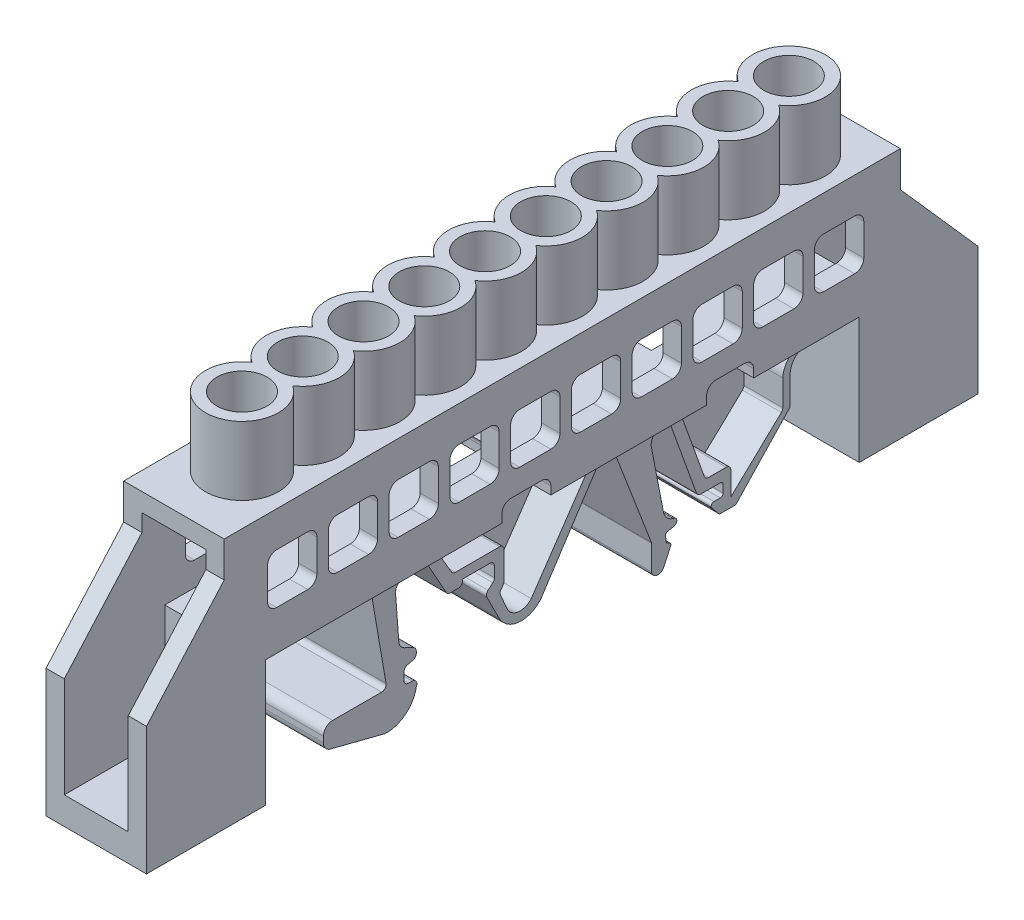
from build123d import *

# Parameters (mm, degrees)
RESSALTO_EXTRUS_O1_DEPTH = 5.5
RESSALTO_EXTRUS_O2_DEPTH = 1
RESSALTO_EXTRUS_O3_DEPTH = 5.25
ESBO_O4_W                = 7
ESBO_O4_H                = 22.5
CORTE_EXTRUS_O1_DEPTH    = 11
ESBO_O5_W                = 7
ESBO_O5_H                = 22.5
CORTE_EXTRUS_O2_DEPTH    = 11
ESBO_O6_W                = 7
ESBO_O6_H                = 10
CORTE_EXTRUS_O3_DEPTH    = 81
ESBO_O7_R                = 2.75
RESSALTO_EXTRUS_O4_DEPTH = 7.5
CORTE_EXTRUS_O4_START    = -3.5
ESBO_O8_R                = 2.75
CORTE_EXTRUS_O4_DEPTH    = 3.5


with BuildPart() as part:
    # Esboço3 → Ressalto-extrusão1 (new, symmetric)
    with BuildSketch(Plane(origin=(0, 0, 0), x_dir=(0, 0, -1), z_dir=(1, 0, 0))):
        with BuildLine():
            Line((0, 14), (0, 0))
            Line((0, 0), (13, 0))
            Line((13, 0), (13, 13.789846595))
            Line((13, 13.789846595), (24.898592819, 13.789846595))
            Line((24.898592819, 13.789846595), (28.503498501, 13.789846595))
            Line((28.503498501, 13.789846595), (30.949413604, 13.789846595))
            Line((30.949413604, 13.789846595), (32.400788305, 13.789846595))
            Line((32.400788305, 13.789846595), (38.891429615, 13.789846595))
            Line((38.891429615, 13.789846595), (38.891429615, 14.669041884))
            ThreePointArc((38.891429615, 14.669041884), (39.184322834, 15.376148665), (39.891429615, 15.669041884))
            Line((39.891429615, 15.669041884), (43.249413604, 15.669041884))
            ThreePointArc((43.249413604, 15.669041884), (43.956520385, 15.376148665), (44.249413604, 14.669041884))
            Line((44.249413604, 14.669041884), (44.249413604, 13.789846595))
            Line((44.249413604, 13.789846595), (48.485767482, 13.789846595))
            Line((48.485767482, 13.789846595), (49.643077993, 13.789846595))
            Line((49.643077993, 13.789846595), (51.577962763, 13.789846595))
            Line((51.577962763, 13.789846595), (55.993250373, 13.789846595))
            Line((55.993250373, 13.789846595), (57.549413604, 13.789846595))
            Line((57.549413604, 13.789846595), (58.827872279, 13.789846595))
            Line((58.827872279, 13.789846595), (61.295441706, 13.789846595))
            Line((61.295441706, 13.789846595), (61.295441706, 14.669041884))
            ThreePointArc((61.295441706, 14.669041884), (61.588334925, 15.376148665), (62.295441706, 15.669041884))
            Line((62.295441706, 15.669041884), (65.449294419, 15.669041884))
            ThreePointArc((65.449294419, 15.669041884), (66.1564012, 15.376148665), (66.449294419, 14.669041884))
            Line((66.449294419, 14.669041884), (66.449294419, 13.789846595))
            Line((66.449294419, 13.789846595), (70.849413604, 13.789846595))
            Line((70.849413604, 13.789846595), (72.110349122, 13.789846595))
            Line((72.110349122, 13.789846595), (78, 13.789846595))
            Line((78, 13.789846595), (78, 0))
            Line((78, 0), (91, 0))
            Line((91, 0), (91, 14))
            Line((91, 14), (82.5, 23.613035938))
            Line((82.5, 23.613035938), (82.5, 27.5))
            Line((82.5, 27.5), (8.5, 27.5))
            Line((8.5, 27.5), (8.5, 23.613035938))
            Line((8.5, 23.613035938), (0, 14))
        make_face()
        with BuildLine():
            ThreePointArc((13.249294419, 22.613035938), (13.542187638, 23.320142719), (14.249294419, 23.613035938))
            Line((14.249294419, 23.613035938), (17.649413604, 23.613035938))
            ThreePointArc((17.649413604, 23.613035938), (18.356520385, 23.320142719), (18.649413604, 22.613035938))
            Line((18.649413604, 22.613035938), (18.649413604, 19.138668257))
            ThreePointArc((18.649413604, 19.138668257), (18.356520385, 18.431561476), (17.649413604, 18.138668257))
            Line((17.649413604, 18.138668257), (14.249294419, 18.138668257))
            ThreePointArc((14.249294419, 18.138668257), (13.542187638, 18.431561476), (13.249294419, 19.138668257))
            Line((13.249294419, 19.138668257), (13.249294419, 22.613035938))
        make_face(mode=Mode.SUBTRACT)
        with BuildLine():
            ThreePointArc((24.299413604, 23.613035938), (25.006520385, 23.320142719), (25.299413604, 22.613035938))
            Line((25.299413604, 22.613035938), (25.299413604, 19.138668257))
            ThreePointArc((25.299413604, 19.138668257), (25.006520385, 18.431561476), (24.299413604, 18.138668257))
            Line((24.299413604, 18.138668257), (20.899294419, 18.138668257))
            ThreePointArc((20.899294419, 18.138668257), (20.192187638, 18.431561476), (19.899294419, 19.138668257))
            Line((19.899294419, 19.138668257), (19.899294419, 22.613035938))
            ThreePointArc((19.899294419, 22.613035938), (20.192187638, 23.320142719), (20.899294419, 23.613035938))
            Line((20.899294419, 23.613035938), (24.299413604, 23.613035938))
        make_face(mode=Mode.SUBTRACT)
        with BuildLine():
            ThreePointArc((30.949413604, 23.613035938), (31.656520385, 23.320142719), (31.949413604, 22.613035938))
            Line((31.949413604, 22.613035938), (31.949413604, 19.138668257))
            ThreePointArc((31.949413604, 19.138668257), (31.656520385, 18.431561476), (30.949413604, 18.138668257))
            Line((30.949413604, 18.138668257), (27.549294419, 18.138668257))
            ThreePointArc((27.549294419, 18.138668257), (26.842187638, 18.431561476), (26.549294419, 19.138668257))
            Line((26.549294419, 19.138668257), (26.549294419, 22.613035938))
            ThreePointArc((26.549294419, 22.613035938), (26.842187638, 23.320142719), (27.549294419, 23.613035938))
            Line((27.549294419, 23.613035938), (30.949413604, 23.613035938))
        make_face(mode=Mode.SUBTRACT)
        with BuildLine():
            ThreePointArc((37.599413604, 23.613035938), (38.306520385, 23.320142719), (38.599413604, 22.613035938))
            Line((38.599413604, 22.613035938), (38.599413604, 19.138668257))
            ThreePointArc((38.599413604, 19.138668257), (38.306520385, 18.431561476), (37.599413604, 18.138668257))
            Line((37.599413604, 18.138668257), (34.199294419, 18.138668257))
            ThreePointArc((34.199294419, 18.138668257), (33.492187638, 18.431561476), (33.199294419, 19.138668257))
            Line((33.199294419, 19.138668257), (33.199294419, 22.613035938))
            ThreePointArc((33.199294419, 22.613035938), (33.492187638, 23.320142719), (34.199294419, 23.613035938))
            Line((34.199294419, 23.613035938), (37.599413604, 23.613035938))
        make_face(mode=Mode.SUBTRACT)
        with BuildLine():
            ThreePointArc((44.249413604, 23.613035938), (44.956520385, 23.320142719), (45.249413604, 22.613035938))
            Line((45.249413604, 22.613035938), (45.249413604, 19.138668257))
            ThreePointArc((45.249413604, 19.138668257), (44.956520385, 18.431561476), (44.249413604, 18.138668257))
            Line((44.249413604, 18.138668257), (40.849294419, 18.138668257))
            ThreePointArc((40.849294419, 18.138668257), (40.142187638, 18.431561476), (39.849294419, 19.138668257))
            Line((39.849294419, 19.138668257), (39.849294419, 22.613035938))
            ThreePointArc((39.849294419, 22.613035938), (40.142187638, 23.320142719), (40.849294419, 23.613035938))
            Line((40.849294419, 23.613035938), (44.249413604, 23.613035938))
        make_face(mode=Mode.SUBTRACT)
        with BuildLine():
            ThreePointArc((50.899413604, 23.613035938), (51.606520385, 23.320142719), (51.899413604, 22.613035938))
            Line((51.899413604, 22.613035938), (51.899413604, 19.138668257))
            ThreePointArc((51.899413604, 19.138668257), (51.606520385, 18.431561476), (50.899413604, 18.138668257))
            Line((50.899413604, 18.138668257), (47.499294419, 18.138668257))
            ThreePointArc((47.499294419, 18.138668257), (46.792187638, 18.431561476), (46.499294419, 19.138668257))
            Line((46.499294419, 19.138668257), (46.499294419, 22.613035938))
            ThreePointArc((46.499294419, 22.613035938), (46.792187638, 23.320142719), (47.499294419, 23.613035938))
            Line((47.499294419, 23.613035938), (50.899413604, 23.613035938))
        make_face(mode=Mode.SUBTRACT)
        with BuildLine():
            ThreePointArc((57.549413604, 23.613035938), (58.256520385, 23.320142719), (58.549413604, 22.613035938))
            Line((58.549413604, 22.613035938), (58.549413604, 19.138668257))
            ThreePointArc((58.549413604, 19.138668257), (58.256520385, 18.431561476), (57.549413604, 18.138668257))
            Line((57.549413604, 18.138668257), (54.149294419, 18.138668257))
            ThreePointArc((54.149294419, 18.138668257), (53.442187638, 18.431561476), (53.149294419, 19.138668257))
            Line((53.149294419, 19.138668257), (53.149294419, 22.613035938))
            ThreePointArc((53.149294419, 22.613035938), (53.442187638, 23.320142719), (54.149294419, 23.613035938))
            Line((54.149294419, 23.613035938), (57.549413604, 23.613035938))
        make_face(mode=Mode.SUBTRACT)
        with BuildLine():
            ThreePointArc((64.199413604, 23.613035938), (64.906520385, 23.320142719), (65.199413604, 22.613035938))
            Line((65.199413604, 22.613035938), (65.199413604, 19.138668257))
            ThreePointArc((65.199413604, 19.138668257), (64.906520385, 18.431561476), (64.199413604, 18.138668257))
            Line((64.199413604, 18.138668257), (60.799294419, 18.138668257))
            ThreePointArc((60.799294419, 18.138668257), (60.092187638, 18.431561476), (59.799294419, 19.138668257))
            Line((59.799294419, 19.138668257), (59.799294419, 22.613035938))
            ThreePointArc((59.799294419, 22.613035938), (60.092187638, 23.320142719), (60.799294419, 23.613035938))
            Line((60.799294419, 23.613035938), (64.199413604, 23.613035938))
        make_face(mode=Mode.SUBTRACT)
        with BuildLine():
            ThreePointArc((70.849413604, 23.613035938), (71.556520385, 23.320142719), (71.849413604, 22.613035938))
            Line((71.849413604, 22.613035938), (71.849413604, 19.138668257))
            ThreePointArc((71.849413604, 19.138668257), (71.556520385, 18.431561476), (70.849413604, 18.138668257))
            Line((70.849413604, 18.138668257), (67.449294419, 18.138668257))
            ThreePointArc((67.449294419, 18.138668257), (66.742187638, 18.431561476), (66.449294419, 19.138668257))
            Line((66.449294419, 19.138668257), (66.449294419, 22.613035938))
            ThreePointArc((66.449294419, 22.613035938), (66.742187638, 23.320142719), (67.449294419, 23.613035938))
            Line((67.449294419, 23.613035938), (70.849413604, 23.613035938))
        make_face(mode=Mode.SUBTRACT)
        with BuildLine():
            ThreePointArc((77.499413604, 23.613035938), (78.206520385, 23.320142719), (78.499413604, 22.613035938))
            Line((78.499413604, 22.613035938), (78.499413604, 19.138668257))
            ThreePointArc((78.499413604, 19.138668257), (78.206520385, 18.431561476), (77.499413604, 18.138668257))
            Line((77.499413604, 18.138668257), (74.099294419, 18.138668257))
            ThreePointArc((74.099294419, 18.138668257), (73.392187638, 18.431561476), (73.099294419, 19.138668257))
            Line((73.099294419, 19.138668257), (73.099294419, 22.613035938))
            ThreePointArc((73.099294419, 22.613035938), (73.392187638, 23.320142719), (74.099294419, 23.613035938))
            Line((74.099294419, 23.613035938), (77.499413604, 23.613035938))
        make_face(mode=Mode.SUBTRACT)
    extrude(amount=RESSALTO_EXTRUS_O1_DEPTH, both=True)

    # Esboço3<3> → Ressalto-extrusão2 (add, symmetric)
    with BuildSketch(Plane(origin=(0, 0, 0), x_dir=(0, 0, -1), z_dir=(1, 0, 0))):
        with BuildLine():
            ThreePointArc((69.885872586, 11.94547112), (70.159995656, 12.976138301), (70.849413604, 13.789846595))
            Line((70.849413604, 13.789846595), (66.449294419, 13.789846595))
            Line((66.449294419, 13.789846595), (66.449294419, 14.669041884))
            ThreePointArc((66.449294419, 14.669041884), (66.1564012, 15.376148665), (65.449294419, 15.669041884))
            Line((65.449294419, 15.669041884), (62.295441706, 15.669041884))
            ThreePointArc((62.295441706, 15.669041884), (61.588334925, 15.376148665), (61.295441706, 14.669041884))
            Line((61.295441706, 14.669041884), (61.295441706, 13.789846595))
            Line((61.295441706, 13.789846595), (58.827872279, 13.789846595))
            Line((58.827872279, 13.789846595), (61.295441706, 6.909975208))
            ThreePointArc((61.295441706, 6.909975208), (61.478336907, 6.669876612), (61.766085315, 6.578778622))
            Line((61.766085315, 6.578778622), (63.699413604, 6.578778622))
            ThreePointArc((63.699413604, 6.578778622), (64.052966995, 6.432332013), (64.199413604, 6.078778622))
            Line((64.199413604, 6.078778622), (64.199413604, 3.510661599))
            Line((64.199413604, 3.510661599), (69.729952437, 8.756124271))
            ThreePointArc((69.729952437, 8.756124271), (69.845241678, 8.921470268), (69.885872586, 9.118903896))
            Line((69.885872586, 9.118903896), (69.885872586, 11.94547112))
        make_face()
        with BuildLine():
            Line((38.891429615, 13.789846595), (32.400788305, 13.789846595))
            Line((32.400788305, 13.789846595), (33.621500031, 11.693837186))
            ThreePointArc((33.621500031, 11.693837186), (33.804383568, 11.511986999), (34.053565261, 11.44547112))
            Line((34.053565261, 11.44547112), (38.891429615, 11.44547112))
            ThreePointArc((38.891429615, 11.44547112), (39.244983006, 11.29902451), (39.391429615, 10.94547112))
            Line((39.391429615, 10.94547112), (39.391429615, 7.946992131))
            ThreePointArc((39.391429615, 7.946992131), (39.364512563, 7.785151083), (39.286659517, 7.640735172))
            Line((39.286659517, 7.640735172), (39.0539077, 7.340364928))
            ThreePointArc((39.0539077, 7.340364928), (38.95320027, 7.097717426), (38.989410815, 6.837508676))
            Line((38.989410815, 6.837508676), (39.722412451, 5.123461371))
            ThreePointArc((39.722412451, 5.123461371), (40.952270853, 4.251004104), (42.356081951, 4.801501857))
            Line((42.356081951, 4.801501857), (48.485767482, 13.789846595))
            Line((48.485767482, 13.789846595), (44.249413604, 13.789846595))
            Line((44.249413604, 13.789846595), (44.249413604, 14.669041884))
            ThreePointArc((44.249413604, 14.669041884), (43.956520385, 15.376148665), (43.249413604, 15.669041884))
            Line((43.249413604, 15.669041884), (39.891429615, 15.669041884))
            ThreePointArc((39.891429615, 15.669041884), (39.184322834, 15.376148665), (38.891429615, 14.669041884))
            Line((38.891429615, 14.669041884), (38.891429615, 13.789846595))
        make_face()
    extrude(amount=RESSALTO_EXTRUS_O2_DEPTH, both=True)

    # Esboço3<4> → Ressalto-extrusão3 (add, symmetric)
    with BuildSketch(Plane(origin=(0, 0, 0), x_dir=(0, 0, -1), z_dir=(1, 0, 0))):
        with BuildLine():
            Line((20.364830397, 1.535810208), (26.343264803, 0))
            Line((26.343264803, 0), (26.73674434, 0))
            ThreePointArc((26.73674434, 0), (28.72569851, 0.827209584), (29.774052255, 2.709008938))
            ThreePointArc((29.774052255, 2.709008938), (29.775216781, 3.23479491), (29.321640723, 3.500729119))
            Line((29.321640723, 3.500729119), (28.916817659, 3.500729119))
            ThreePointArc((28.916817659, 3.500729119), (28.563264268, 3.647175729), (28.416817659, 4.000729119))
            Line((28.416817659, 4.000729119), (28.416817659, 4.801501857))
            ThreePointArc((28.416817659, 4.801501857), (28.524770774, 5.111823046), (28.80201462, 5.288143679))
            Line((28.80201462, 5.288143679), (29.390019819, 5.42685922))
            ThreePointArc((29.390019819, 5.42685922), (29.667263665, 5.603179852), (29.775216781, 5.913501041))
            Line((29.775216781, 5.913501041), (29.775216781, 6.130093383))
            ThreePointArc((29.775216781, 6.130093383), (29.699669067, 6.394366456), (29.495855754, 6.578778622))
            Line((29.495855754, 6.578778622), (28.419840727, 7.107904232))
            ThreePointArc((28.419840727, 7.107904232), (28.032516369, 7.445437035), (27.863900389, 7.930738182))
            Line((27.863900389, 7.930738182), (27.506280217, 12.715310068))
            ThreePointArc((27.506280217, 12.715310068), (27.770512646, 13.470090475), (28.503498501, 13.789846595))
            Line((28.503498501, 13.789846595), (24.898592819, 13.789846595))
            Line((24.898592819, 13.789846595), (26.465396769, 4.707797613))
            ThreePointArc((26.465396769, 4.707797613), (26.355102519, 4.300693531), (25.972675193, 4.122794976))
            Line((25.972675193, 4.122794976), (20.613643263, 4.122794976))
            ThreePointArc((20.613643263, 4.122794976), (19.906536482, 3.829901757), (19.613643263, 3.122794976))
            Line((19.613643263, 3.122794976), (19.613643263, 2.504361785))
            ThreePointArc((19.613643263, 2.504361785), (19.823449342, 1.891504896), (20.364830397, 1.535810208))
        make_face()
        with BuildLine():
            Line((32.400788305, 13.789846595), (30.949413604, 13.789846595))
            Line((30.949413604, 13.789846595), (33.056122431, 10.026029802))
            ThreePointArc((33.056122431, 10.026029802), (33.239548281, 9.838902414), (33.49242626, 9.770240712))
            Line((33.49242626, 9.770240712), (34.358917872, 9.770240712))
            ThreePointArc((34.358917872, 9.770240712), (34.712471263, 9.916687322), (34.858917872, 10.270240712))
            Line((34.858917872, 10.270240712), (34.858917872, 10.409230932))
            Line((34.858917872, 10.409230932), (37.827721923, 10.409230932))
            ThreePointArc((37.827721923, 10.409230932), (38.181275314, 10.262784323), (38.327721923, 9.909230932))
            Line((38.327721923, 9.909230932), (38.327721923, 8.784603909))
            ThreePointArc((38.327721923, 8.784603909), (38.281453321, 8.574537683), (38.151210647, 8.403349341))
            Line((38.151210647, 8.403349341), (37.623691652, 7.955757466))
            ThreePointArc((37.623691652, 7.955757466), (37.457180698, 7.674003227), (37.50060785, 7.34961853))
            Line((37.50060785, 7.34961853), (38.873777842, 4.622794976))
            ThreePointArc((38.873777842, 4.622794976), (41.077358627, 3.236599568), (43.4495558, 4.308973829))
            Line((43.4495558, 4.308973829), (49.643077993, 13.789846595))
            Line((49.643077993, 13.789846595), (48.485767482, 13.789846595))
            Line((48.485767482, 13.789846595), (42.356081951, 4.801501857))
            ThreePointArc((42.356081951, 4.801501857), (40.952270853, 4.251004104), (39.722412451, 5.123461371))
            Line((39.722412451, 5.123461371), (38.989410815, 6.837508676))
            ThreePointArc((38.989410815, 6.837508676), (38.95320027, 7.097717426), (39.0539077, 7.340364928))
            Line((39.0539077, 7.340364928), (39.286659517, 7.640735172))
            ThreePointArc((39.286659517, 7.640735172), (39.364512563, 7.785151083), (39.391429615, 7.946992131))
            Line((39.391429615, 7.946992131), (39.391429615, 10.94547112))
            ThreePointArc((39.391429615, 10.94547112), (39.244983006, 11.29902451), (38.891429615, 11.44547112))
            Line((38.891429615, 11.44547112), (34.053565261, 11.44547112))
            ThreePointArc((34.053565261, 11.44547112), (33.804383568, 11.511986999), (33.621500031, 11.693837186))
            Line((33.621500031, 11.693837186), (32.400788305, 13.789846595))
        make_face()
        with BuildLine():
            ThreePointArc((70.680059627, 11.94547112), (71.112564532, 13.086842425), (72.110349122, 13.789846595))
            Line((72.110349122, 13.789846595), (70.849413604, 13.789846595))
            ThreePointArc((70.849413604, 13.789846595), (70.159995656, 12.976138301), (69.885872586, 11.94547112))
            Line((69.885872586, 11.94547112), (69.885872586, 9.118903896))
            ThreePointArc((69.885872586, 9.118903896), (69.845241678, 8.921470268), (69.729952437, 8.756124271))
            Line((69.729952437, 8.756124271), (64.199413604, 3.510661599))
            Line((64.199413604, 3.510661599), (64.199413604, 6.078778622))
            ThreePointArc((64.199413604, 6.078778622), (64.052966995, 6.432332013), (63.699413604, 6.578778622))
            Line((63.699413604, 6.578778622), (61.766085315, 6.578778622))
            ThreePointArc((61.766085315, 6.578778622), (61.478336907, 6.669876612), (61.295441706, 6.909975208))
            Line((61.295441706, 6.909975208), (58.827872279, 13.789846595))
            Line((58.827872279, 13.789846595), (57.549413604, 13.789846595))
            Line((57.549413604, 13.789846595), (60.437343422, 5.757688627))
            ThreePointArc((60.437343422, 5.757688627), (60.620266317, 5.51784498), (60.907855176, 5.42685922))
            Line((60.907855176, 5.42685922), (63.049825964, 5.42685922))
            ThreePointArc((63.049825964, 5.42685922), (63.261957998, 5.338991254), (63.349825964, 5.12685922))
            Line((63.349825964, 5.12685922), (63.349825964, 4.300729119))
            ThreePointArc((63.349825964, 4.300729119), (63.261957998, 4.088597085), (63.049825964, 4.000729119))
            Line((63.049825964, 4.000729119), (62.351813887, 4.000729119))
            ThreePointArc((62.351813887, 4.000729119), (62.080686374, 3.829142016), (62.119705426, 3.510661599))
            Line((62.119705426, 3.510661599), (62.857536224, 2.609630372))
            ThreePointArc((62.857536224, 2.609630372), (62.961231789, 2.52857038), (63.089644685, 2.499697892))
            Line((63.089644685, 2.499697892), (64.606237924, 2.499697892))
            ThreePointArc((64.606237924, 2.499697892), (64.724886526, 2.524157498), (64.824187808, 2.593547831))
            Line((64.824187808, 2.593547831), (70.598009512, 8.697857327))
            ThreePointArc((70.598009512, 8.697857327), (70.65879334, 8.793068138), (70.680059627, 8.904007388))
            Line((70.680059627, 8.904007388), (70.680059627, 11.94547112))
        make_face()
        with BuildLine():
            Line((55.993250373, 13.789846595), (51.577962763, 13.789846595))
            Line((51.577962763, 13.789846595), (55.508936607, 3.543968186))
            ThreePointArc((55.508936607, 3.543968186), (55.521343576, 3.499954353), (55.525525876, 3.45441691))
            Line((55.525525876, 3.45441691), (55.525525876, 0.750710808))
            ThreePointArc((55.525525876, 0.750710808), (56.056326367, 0.137710586), (56.810855647, 0.434702164))
            Line((56.810855647, 0.434702164), (57.613675208, 2.167772962))
            ThreePointArc((57.613675208, 2.167772962), (57.621538409, 2.35895304), (57.491913801, 2.499697892))
            Line((57.491913801, 2.499697892), (57.275171343, 2.600100649))
            ThreePointArc((57.275171343, 2.600100649), (57.179454624, 2.678014405), (57.132675687, 2.792224627))
            Line((57.132675687, 2.792224627), (57.045319323, 3.415149953))
            ThreePointArc((57.045319323, 3.415149953), (57.088883788, 3.594363833), (57.243481821, 3.694936819))
            Line((57.243481821, 3.694936819), (58.052215107, 3.85800806))
            ThreePointArc((58.052215107, 3.85800806), (58.280744844, 4.302029048), (57.898005118, 4.622794976))
            ThreePointArc((57.898005118, 4.622794976), (57.180067867, 5.066456588), (56.810855647, 5.825371511))
            Line((56.810855647, 5.825371511), (55.525525876, 12.471135232))
            ThreePointArc((55.525525876, 12.471135232), (55.553034674, 13.203680973), (55.993250373, 13.789846595))
        make_face()
    extrude(amount=RESSALTO_EXTRUS_O3_DEPTH, both=True)

    # Esboço4 → Corte-extrusão1 (cut)
    with BuildSketch(Plane.XY):
        with Locations((0, 14.25)):
            Rectangle(ESBO_O4_W, ESBO_O4_H)
    extrude(amount=-CORTE_EXTRUS_O1_DEPTH, mode=Mode.SUBTRACT)

    # Esboço5 → Corte-extrusão2 (cut)
    with BuildSketch(Plane(origin=(0, 0, -91), x_dir=(-1, 0, 0), z_dir=(0, 0, -1))):
        with Locations((0, 14.25)):
            Rectangle(ESBO_O5_W, ESBO_O5_H)
    extrude(amount=-CORTE_EXTRUS_O2_DEPTH, mode=Mode.SUBTRACT)

    # Esboço6 → Corte-extrusão3 (cut)
    with BuildSketch(Plane(origin=(0, 0, -80), x_dir=(-1, 0, 0), z_dir=(0, 0, -1))):
        with Locations((0, 20.5)):
            Rectangle(ESBO_O6_W, ESBO_O6_H)
    extrude(amount=-CORTE_EXTRUS_O3_DEPTH, mode=Mode.SUBTRACT)

    # Esboço7 → Ressalto-extrusão4 (add)
    with BuildSketch(Plane(origin=(0, 27.5, 0), x_dir=(1, 0, 0), z_dir=(0, 1, 0))):
        with BuildLine():
            ThreePointArc((-2.223595062, 19.274354011), (0, 11.949354011), (2.223595062, 19.274354011))
            ThreePointArc((2.223595062, 19.274354011), (4, 22.599354011), (2.223595062, 25.924354011))
            ThreePointArc((2.223595062, 25.924354011), (4, 29.249354011), (2.223595062, 32.574354011))
            ThreePointArc((2.223595062, 32.574354011), (4, 35.899354011), (2.223595062, 39.224354011))
            ThreePointArc((2.223595062, 39.224354011), (4, 42.549354011), (2.223595062, 45.874354011))
            ThreePointArc((2.223595062, 45.874354011), (4, 49.199354011), (2.223595062, 52.524354011))
            ThreePointArc((2.223595062, 52.524354011), (4, 55.849354011), (2.223595062, 59.174354011))
            ThreePointArc((2.223595062, 59.174354011), (4, 62.499354011), (2.223595062, 65.824354011))
            ThreePointArc((2.223595062, 65.824354011), (4, 69.149354011), (2.223595062, 72.474354011))
            ThreePointArc((2.223595062, 72.474354011), (0, 79.799354011), (-2.223595062, 72.474354011))
            ThreePointArc((-2.223595062, 72.474354011), (-4, 69.149354011), (-2.223595062, 65.824354011))
            ThreePointArc((-2.223595062, 65.824354011), (-4, 62.499354011), (-2.223595062, 59.174354011))
            ThreePointArc((-2.223595062, 59.174354011), (-4, 55.849354011), (-2.223595062, 52.524354011))
            ThreePointArc((-2.223595062, 52.524354011), (-4, 49.199354011), (-2.223595062, 45.874354011))
            ThreePointArc((-2.223595062, 45.874354011), (-4, 42.549354011), (-2.223595062, 39.224354011))
            ThreePointArc((-2.223595062, 39.224354011), (-4, 35.899354011), (-2.223595062, 32.574354011))
            ThreePointArc((-2.223595062, 32.574354011), (-4, 29.249354011), (-2.223595062, 25.924354011))
            ThreePointArc((-2.223595062, 25.924354011), (-4, 22.599354011), (-2.223595062, 19.274354011))
        make_face()
        with Locations((0, 15.949354011)):
            Circle(ESBO_O7_R, mode=Mode.SUBTRACT)
        with Locations((0, 22.599354011)):
            Circle(ESBO_O7_R, mode=Mode.SUBTRACT)
        with Locations((0, 29.249354011)):
            Circle(ESBO_O7_R, mode=Mode.SUBTRACT)
        with Locations((0, 35.899354011)):
            Circle(ESBO_O7_R, mode=Mode.SUBTRACT)
        with Locations((0, 42.549354011)):
            Circle(ESBO_O7_R, mode=Mode.SUBTRACT)
        with Locations((0, 49.199354011)):
            Circle(ESBO_O7_R, mode=Mode.SUBTRACT)
        with Locations((0, 55.849354011)):
            Circle(ESBO_O7_R, mode=Mode.SUBTRACT)
        with Locations((0, 62.499354011)):
            Circle(ESBO_O7_R, mode=Mode.SUBTRACT)
        with Locations((0, 69.149354011)):
            Circle(ESBO_O7_R, mode=Mode.SUBTRACT)
        with Locations((0, 75.799354011)):
            Circle(ESBO_O7_R, mode=Mode.SUBTRACT)
    extrude(amount=RESSALTO_EXTRUS_O4_DEPTH)

    # Esboço8 → Corte-extrusão4 (cut)
    with BuildSketch(Plane(origin=(0, 27.5, 0), x_dir=(1, 0, 0), z_dir=(0, 1, 0)).offset(CORTE_EXTRUS_O4_START)):
        with Locations((0, 15.949354011)):
            Circle(ESBO_O8_R)
        with Locations((0, 22.599354011)):
            Circle(ESBO_O8_R)
        with Locations((0, 29.249354011)):
            Circle(ESBO_O8_R)
        with Locations((0, 35.899354011)):
            Circle(ESBO_O8_R)
        with Locations((0, 42.549354011)):
            Circle(ESBO_O8_R)
        with Locations((0, 49.199354011)):
            Circle(ESBO_O8_R)
        with Locations((0, 55.849354011)):
            Circle(ESBO_O8_R)
        with Locations((0, 62.499354011)):
            Circle(ESBO_O8_R)
        with Locations((0, 69.149354011)):
            Circle(ESBO_O8_R)
        with Locations((0, 75.799354011)):
            Circle(ESBO_O8_R)
    extrude(amount=CORTE_EXTRUS_O4_DEPTH, mode=Mode.SUBTRACT)


solid = part.part
